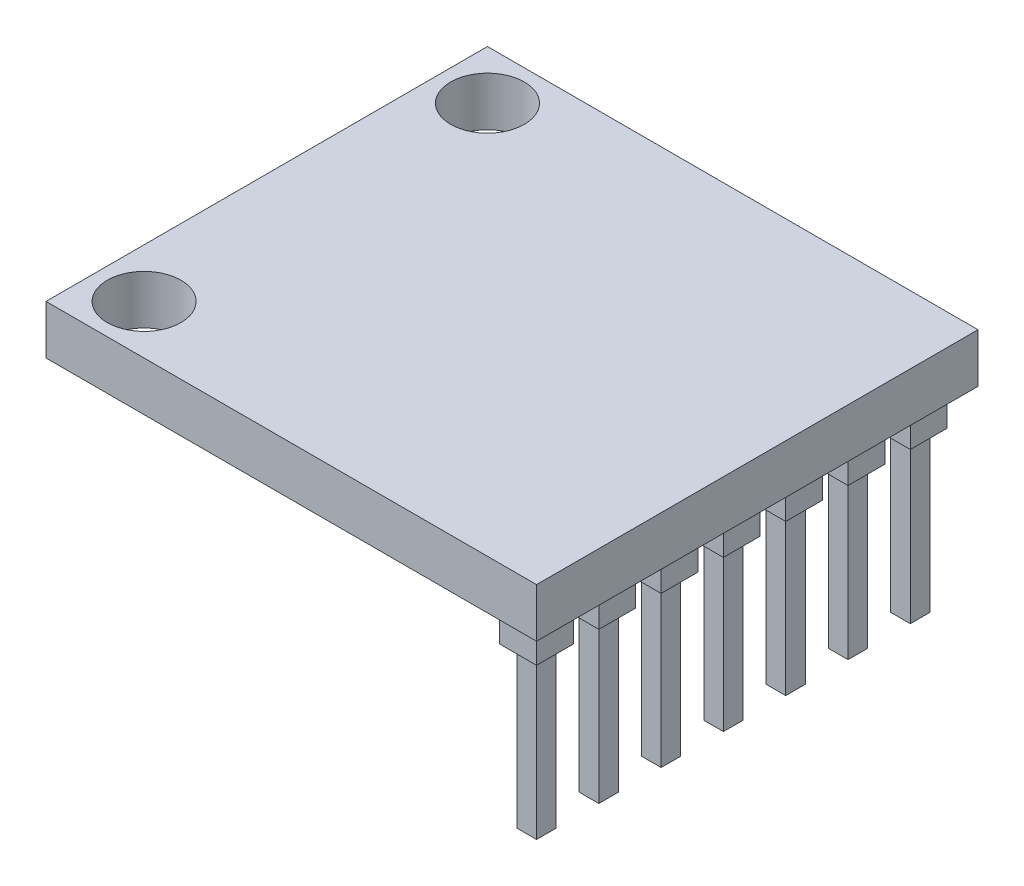
from build123d import *

# Parameters (mm, degrees)
SKIZZE1_W                       = 20
SKIZZE1_H                       = 18
SKIZZE1_R                       = 1.5
AUFSATZ_LINEAR_AUSTRAGEN1_DEPTH = 2
SKIZZE2_W                       = 0.8
SKIZZE2_H                       = 0.8
AUFSATZ_LINEAR_AUSTRAGEN2_DEPTH = 8
SKIZZE3_W                       = 1.5
SKIZZE3_H                       = 1.5
AUFSATZ_LINEAR_AUSTRAGEN3_DEPTH = 1.5
LINEARES_MUSTER1_COUNT          = 7
LINEARES_MUSTER1_PITCH          = 2.54


with BuildPart() as part:
    # Skizze1 → Aufsatz-Linear austragen1 (new body)
    with BuildSketch(Plane(origin=(0, 0, 0), x_dir=(1, 0, 0), z_dir=(0, 1, 0))):
        Rectangle(SKIZZE1_W, SKIZZE1_H)
        with Locations((-8, -7)):
            Circle(SKIZZE1_R, mode=Mode.SUBTRACT)
        with Locations((-8, 7)):
            Circle(SKIZZE1_R, mode=Mode.SUBTRACT)
    extrude(amount=AUFSATZ_LINEAR_AUSTRAGEN1_DEPTH)

    # Skizze2 → Aufsatz-Linear austragen2 (add)
    with BuildSketch(Plane.XZ):
        with Locations((8.6, 7.6)):
            Rectangle(SKIZZE2_W, SKIZZE2_H)
    aufsatz_linear_austragen2 = extrude(amount=AUFSATZ_LINEAR_AUSTRAGEN2_DEPTH)

    # Skizze3 → Aufsatz-Linear austragen3 (add)
    with BuildSketch(Plane(origin=(0, 0, 0), x_dir=(-1, 0, 0), z_dir=(0, -1, 0))):
        with Locations((-8.6, -7.6)):
            Rectangle(SKIZZE3_W, SKIZZE3_H)
    aufsatz_linear_austragen3 = extrude(amount=AUFSATZ_LINEAR_AUSTRAGEN3_DEPTH)

    # Lineares Muster1: Aufsatz-Linear austragen2, Aufsatz-Linear austragen3 ×7
    with Locations(*[(0, 0, -i * LINEARES_MUSTER1_PITCH) for i in range(1, LINEARES_MUSTER1_COUNT)]):
        add(aufsatz_linear_austragen2)
        add(aufsatz_linear_austragen3)


solid = part.part
